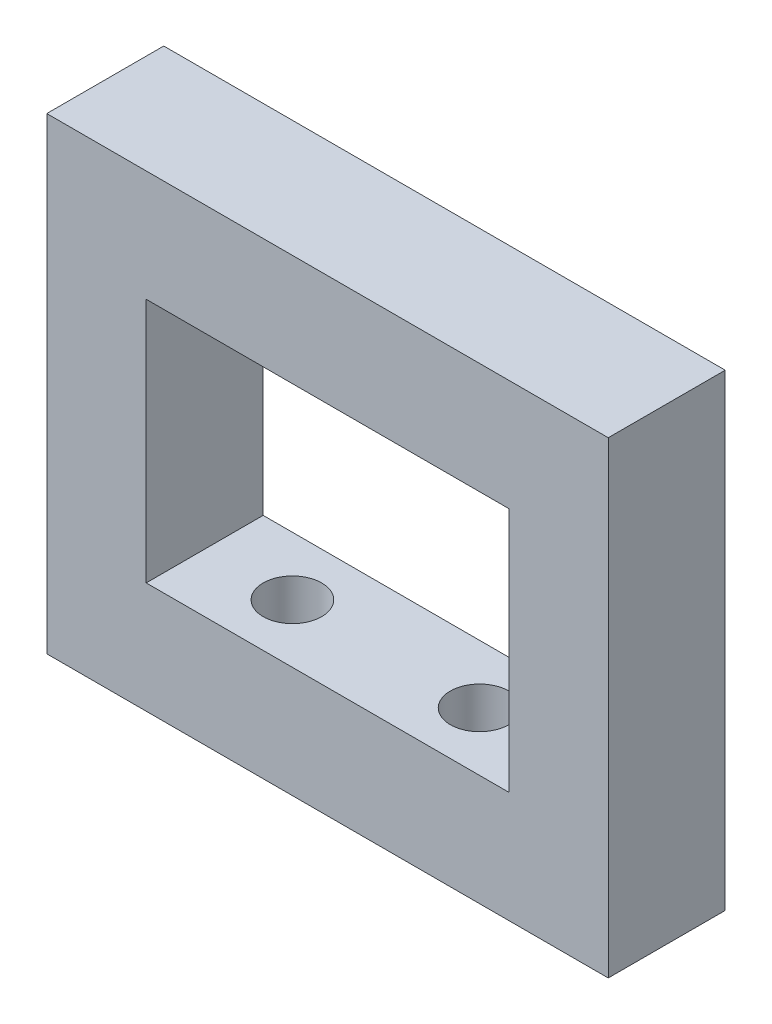
from build123d import *

# Parameters (mm, degrees)
SKETCH_1_W          = 24
SKETCH_1_H          = 20
EXTRUDE_1_DEPTH     = 2.5
SKETCH_2_W          = 15.5
SKETCH_2_H          = 10.5
CUT_EXTRUDE_1_DEPTH = 6
CUT_EXTRUDE_2_REACH = 22
SKETCH_4_R          = 1.25


with BuildPart() as part:
    # 草圖1 → 填料-伸長1 (new body, symmetric)
    with BuildSketch(Plane.XY):
        Rectangle(SKETCH_1_W, SKETCH_1_H)
    extrude(amount=EXTRUDE_1_DEPTH, both=True)

    # 草圖2 → 除料-伸長1 (cut, through all)
    with BuildSketch(Plane.XY.offset(2.5)):
        Rectangle(SKETCH_2_W, SKETCH_2_H)
    extrude(amount=-CUT_EXTRUDE_1_DEPTH, mode=Mode.SUBTRACT)

    # 草圖4 → 除料-伸長2 (cut, up to next)
    with BuildSketch(Plane.XZ.offset(10), mode=Mode.PRIVATE) as cut_extrude_2_sk1:
        with Locations((-4, 0)):
            Circle(SKETCH_4_R)
    cut_extrude_2_tool1 = extrude(cut_extrude_2_sk1.sketch, amount=-CUT_EXTRUDE_2_REACH, mode=Mode.PRIVATE) & part.part
    add(cut_extrude_2_tool1.solids().sort_by_distance((-4, -10, 0))[0], mode=Mode.SUBTRACT)
    # 草圖4 → 除料-伸長2 (cut, up to next)
    with BuildSketch(Plane.XZ.offset(10), mode=Mode.PRIVATE) as cut_extrude_2_sk2:
        with Locations((4, 0)):
            Circle(SKETCH_4_R)
    cut_extrude_2_tool2 = extrude(cut_extrude_2_sk2.sketch, amount=-CUT_EXTRUDE_2_REACH, mode=Mode.PRIVATE) & part.part
    add(cut_extrude_2_tool2.solids().sort_by_distance((4, -10, 0))[0], mode=Mode.SUBTRACT)


solid = part.part
